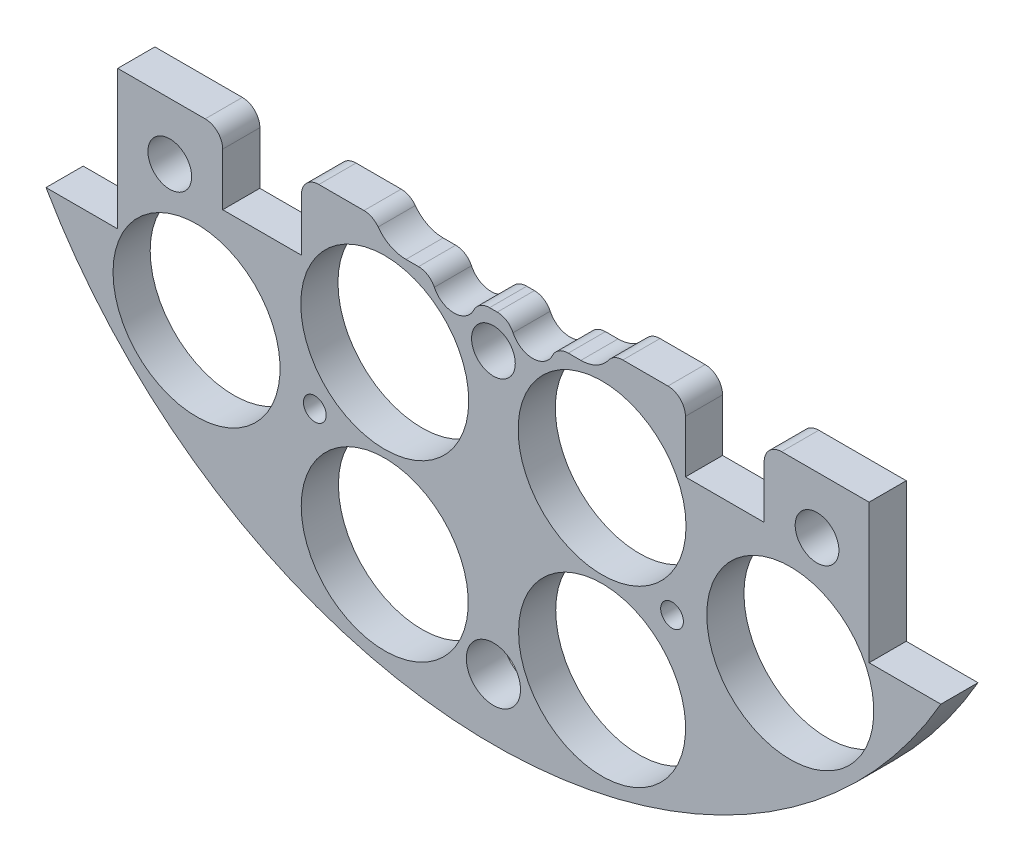
from build123d import *

# Parameters (mm, degrees)
SKETCH1_R                = 1.651
BOSS_EXTRUDE2_DEPTH      = 5.3975
SKETCH2_R                = 1.143
CUT_EXTRUDE1_DEPTH       = 6.3975
SKETCH3_R                = 12.1285
CUT_EXTRUDE2_DEPTH       = 6.3975
SKETCH4_W                = 28.562713242
SKETCH4_H                = 11.677503754
BOSS_EXTRUDE3_DEPTH      = 5.3975
SKETCH5_W                = 216.7214489
SKETCH5_H                = 130.569220634
CUT_EXTRUDE4_DEPTH       = 6.3975
SKETCH11_R               = 3.937
CUT_EXTRUDE11_DEPTH      = 6.3975
SKETCH12_W               = 11.43
SKETCH12_H               = 10.16
CUT_EXTRUDE12_DEPTH      = 6.3975
SKETCH16_R               = 12.192
CUT_EXTRUDE16_DEPTH      = 21.59
SKETCH57_R               = 1.651
CUT_EXTRUDE57_DEPTH      = 58.674
SKETCH58_R               = 3.175
CUT_EXTRUDE58_DEPTH      = 103.378
CUT_EXTRUDE58_DEPTH_BACK = 48.768
CUT_EXTRUDE15_DEPTH      = 21.59
FILLET1_R                = 2.54


with BuildPart() as part:
    # Sketch1 → Boss-Extrude2 (new body)
    with BuildSketch(Plane.XY):
        with BuildLine():
            Line((-64.964441474, 37.338), (-54.550441474, 37.338))
            Line((-54.550441474, 37.338), (-54.550441474, -37.338))
            Line((-54.550441474, -37.338), (-64.964441474, -37.338))
            ThreePointArc((-64.964441474, -37.338), (0, -74.93), (64.964441474, -37.338))
            Line((64.964441474, -37.338), (54.550441474, -37.338))
            Line((54.550441474, -37.338), (54.550441474, 37.338))
            Line((54.550441474, 37.338), (64.964441474, 37.338))
            ThreePointArc((64.964441474, 37.338), (0, 74.93), (-64.964441474, 37.338))
        make_face()
        with Locations((-46.482, 11.049)):
            Circle(SKETCH1_R, mode=Mode.SUBTRACT)
        with Locations((-21.083270032, 10.795)):
            Circle(SKETCH1_R, mode=Mode.SUBTRACT)
        with Locations((-21.083270032, -10.795)):
            Circle(SKETCH1_R, mode=Mode.SUBTRACT)
        with Locations((-46.482, -11.049)):
            Circle(SKETCH1_R, mode=Mode.SUBTRACT)
        with Locations((46.482, -11.049)):
            Circle(SKETCH1_R, mode=Mode.SUBTRACT)
        with Locations((21.083270032, -10.795)):
            Circle(SKETCH1_R, mode=Mode.SUBTRACT)
        with Locations((21.083270032, 10.795)):
            Circle(SKETCH1_R, mode=Mode.SUBTRACT)
        with Locations((46.482, 11.049)):
            Circle(SKETCH1_R, mode=Mode.SUBTRACT)
    extrude(amount=BOSS_EXTRUDE2_DEPTH)

    # Sketch2 → Cut-Extrude1 (cut, through all)
    with BuildSketch(Plane.XY.offset(5.3975)):
        with Locations((-6.731, 62.23)):
            Circle(SKETCH2_R)
        with Locations((6.731, 62.23)):
            Circle(SKETCH2_R)
    extrude(amount=-CUT_EXTRUDE1_DEPTH, mode=Mode.SUBTRACT)

    # Sketch3 → Cut-Extrude2 (cut, through all)
    with BuildSketch(Plane(origin=(0, 0, 0), x_dir=(-1, 0, 0), z_dir=(0, 0, -1))):
        with Locations((-15.777608989, -58.882838371)):
            Circle(SKETCH3_R)
        with Locations((15.777608989, -58.882838371)):
            Circle(SKETCH3_R)
        with Locations((-43.105229381, -43.105229381)):
            Circle(SKETCH3_R)
        with Locations((-43.105229381, 43.105229381)):
            Circle(SKETCH3_R)
        with Locations((43.105229381, 43.105229381)):
            Circle(SKETCH3_R)
        with Locations((43.105229381, -43.105229381)):
            Circle(SKETCH3_R)
    extrude(amount=-CUT_EXTRUDE2_DEPTH, mode=Mode.SUBTRACT)

    # Sketch4 → Boss-Extrude3 (add)
    with BuildSketch(Plane(origin=(0, 0, 0), x_dir=(-1, 0, 0), z_dir=(0, 0, -1))):
        with Locations((-1.488809975, 62.152540216)):
            Rectangle(SKETCH4_W, SKETCH4_H)
    extrude(amount=-BOSS_EXTRUDE3_DEPTH)

    # Sketch5 → Cut-Extrude4 (cut, through all)
    with BuildSketch(Plane(origin=(0, 0, 0), x_dir=(-1, 0, 0), z_dir=(0, 0, -1))):
        with Locations((23.316688373, 48.139610317)):
            Rectangle(SKETCH5_W, SKETCH5_H)
    extrude(amount=-CUT_EXTRUDE4_DEPTH, mode=Mode.SUBTRACT)

    # Sketch11 → Cut-Extrude11 (cut, through all)
    with BuildSketch(Plane(origin=(0, 0, 0), x_dir=(-1, 0, 0), z_dir=(0, 0, -1))):
        with Locations((0, -66.045)):
            Circle(SKETCH11_R)
    extrude(amount=-CUT_EXTRUDE11_DEPTH, mode=Mode.SUBTRACT)

    # Sketch12 → Cut-Extrude12 (cut, through all)
    with BuildSketch(Plane(origin=(0, 0, 0), x_dir=(-1, 0, 0), z_dir=(0, 0, -1))):
        with Locations((-33.595441474, -22.225)):
            Rectangle(SKETCH12_W, SKETCH12_H)
        with Locations((33.595441474, -22.225)):
            Rectangle(SKETCH12_W, SKETCH12_H)
    extrude(amount=-CUT_EXTRUDE12_DEPTH, mode=Mode.SUBTRACT)

    # Sketch16 → Cut-Extrude16 (cut)
    with BuildSketch(Plane(origin=(0, 0, 0), x_dir=(-1, 0, 0), z_dir=(0, 0, -1))):
        with Locations((15.777608989, -33.482838371)):
            Circle(SKETCH16_R)
        with Locations((-15.777608989, -33.482838371)):
            Circle(SKETCH16_R)
    extrude(amount=-CUT_EXTRUDE16_DEPTH, mode=Mode.SUBTRACT)

    # Sketch57 → Cut-Extrude57 (cut)
    with BuildSketch(Plane(origin=(0, 0, 0), x_dir=(-1, 0, 0), z_dir=(0, 0, -1))):
        with Locations((-25.937608989, -45.645229381)):
            Circle(SKETCH57_R)
        with Locations((25.937608989, -45.645229381)):
            Circle(SKETCH57_R)
    extrude(amount=-CUT_EXTRUDE57_DEPTH, mode=Mode.SUBTRACT)

    # Sketch58 → Cut-Extrude58 (cut, two sides)
    with BuildSketch(Plane(origin=(30.092005081, 4.08352975, 36.1315), x_dir=(-1, 0, 0), z_dir=(0, 0, -1))) as cut_extrude58_sk:
        with Locations((77.082005081, -29.48352975)):
            Circle(SKETCH58_R)
        with Locations((30.092005081, -29.48352975)):
            Circle(SKETCH58_R)
        with Locations((-16.897994919, -29.48352975)):
            Circle(SKETCH58_R)
    extrude(amount=CUT_EXTRUDE58_DEPTH, mode=Mode.SUBTRACT)
    extrude(cut_extrude58_sk.sketch, amount=-CUT_EXTRUDE58_DEPTH_BACK, mode=Mode.SUBTRACT)

    # Sketch15 → Cut-Extrude15 (cut)
    with BuildSketch(Plane(origin=(0, 0, 0), x_dir=(-1, 0, 0), z_dir=(0, 0, -1))):
        with BuildLine():
            Line((-12.7, -20.24), (-8.888991966, -20.24))
            ThreePointArc((-8.888991966, -20.24), (-5.715, -23.495), (-2.541008034, -20.24))
            Line((-2.541008034, -20.24), (2.541008034, -20.24))
            ThreePointArc((2.541008034, -20.24), (5.715, -23.495), (8.888991966, -20.24))
            Line((8.888991966, -20.24), (12.7, -20.24))
            ThreePointArc((12.7, -20.24), (16.235533906, -11.704466094), (7.7, -15.24))
            Line((7.7, -15.24), (-1.06, -15.24))
            ThreePointArc((-1.06, -15.24), (-4.010609847, -10.6792983), (-9.38, -11.501337137))
            ThreePointArc((-9.38, -11.501337137), (-17.374040774, -13.464234575), (-12.7, -20.24))
        make_face()
    extrude(amount=-CUT_EXTRUDE15_DEPTH, mode=Mode.SUBTRACT)

    # Fillet1
    fillet1_edges = [part.edges().sort_by_distance(p)[0] for p in [
        (39.310441474, -17.145, 2.69875),
        (27.880441474, -17.145, 2.69875),
        (-27.880441474, -17.145, 2.69875),
        (-39.310441474, -17.145, 2.69875),
        (-17.322875188, -17.145, 2.69875),
        (17.322875188, -17.145, 2.69875),
        (-8.888991966, -20.24, 2.69875),
        (-2.541008034, -20.24, 2.69875),
        (2.541008034, -20.24, 2.69875),
        (8.888991966, -20.24, 2.69875),
    ]]
    fillet(fillet1_edges, radius=FILLET1_R)


solid = part.part
